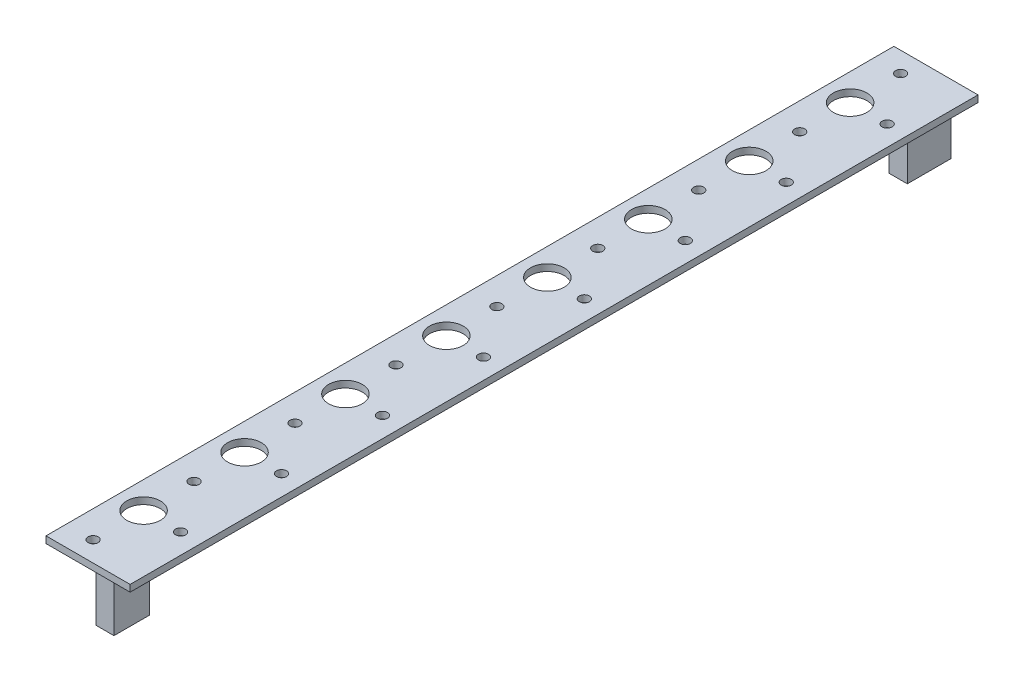
from build123d import *

# Parameters (mm, degrees)
ESQUISSE1_W        = 25
ESQUISSE1_H        = 252
ESQUISSE1_R        = 5
ESQUISSE1_R_2      = 1.5
BOSS_EXTRU_1_DEPTH = 2
ESQUISSE2_W        = 5.4
ESQUISSE2_H        = 13
ESQUISSE2_H_2      = 10.6
BOSS_EXTRU_2_DEPTH = 16


with BuildPart() as part:
    # Esquisse1 → Boss.-Extru.1 (new body)
    with BuildSketch(Plane(origin=(0, 0, 0), x_dir=(1, 0, 0), z_dir=(0, 1, 0))):
        Rectangle(ESQUISSE1_W, ESQUISSE1_H)
        with Locations((-4.5, 105)):
            Circle(ESQUISSE1_R, mode=Mode.SUBTRACT)
        with Locations((6.5, 105)):
            Circle(ESQUISSE1_R_2, mode=Mode.SUBTRACT)
        with Locations((-4.5, 75)):
            Circle(ESQUISSE1_R, mode=Mode.SUBTRACT)
        with Locations((6.5, 75)):
            Circle(ESQUISSE1_R_2, mode=Mode.SUBTRACT)
        with Locations((-4.5, 45)):
            Circle(ESQUISSE1_R, mode=Mode.SUBTRACT)
        with Locations((6.5, 45)):
            Circle(ESQUISSE1_R_2, mode=Mode.SUBTRACT)
        with Locations((-4.5, 15)):
            Circle(ESQUISSE1_R, mode=Mode.SUBTRACT)
        with Locations((6.5, 15)):
            Circle(ESQUISSE1_R_2, mode=Mode.SUBTRACT)
        with Locations((-4.5, -15)):
            Circle(ESQUISSE1_R, mode=Mode.SUBTRACT)
        with Locations((6.5, -15)):
            Circle(ESQUISSE1_R_2, mode=Mode.SUBTRACT)
        with Locations((-4.5, -45)):
            Circle(ESQUISSE1_R, mode=Mode.SUBTRACT)
        with Locations((6.5, -45)):
            Circle(ESQUISSE1_R_2, mode=Mode.SUBTRACT)
        with Locations((-4.5, -75)):
            Circle(ESQUISSE1_R, mode=Mode.SUBTRACT)
        with Locations((6.5, -75)):
            Circle(ESQUISSE1_R_2, mode=Mode.SUBTRACT)
        with Locations((-4.5, -105)):
            Circle(ESQUISSE1_R, mode=Mode.SUBTRACT)
        with Locations((6.5, -105)):
            Circle(ESQUISSE1_R_2, mode=Mode.SUBTRACT)
        with Locations((-4.5, 120)):
            Circle(ESQUISSE1_R_2, mode=Mode.SUBTRACT)
        with Locations((-4.5, 90)):
            Circle(ESQUISSE1_R_2, mode=Mode.SUBTRACT)
        with Locations((-4.5, 60)):
            Circle(ESQUISSE1_R_2, mode=Mode.SUBTRACT)
        with Locations((-4.5, 30)):
            Circle(ESQUISSE1_R_2, mode=Mode.SUBTRACT)
        with Locations((-4.5, 0)):
            Circle(ESQUISSE1_R_2, mode=Mode.SUBTRACT)
        with Locations((-4.5, -30)):
            Circle(ESQUISSE1_R_2, mode=Mode.SUBTRACT)
        with Locations((-4.5, -60)):
            Circle(ESQUISSE1_R_2, mode=Mode.SUBTRACT)
        with Locations((-4.5, -90)):
            Circle(ESQUISSE1_R_2, mode=Mode.SUBTRACT)
        with Locations((-4.5, -120)):
            Circle(ESQUISSE1_R_2, mode=Mode.SUBTRACT)
    extrude(amount=BOSS_EXTRU_1_DEPTH)

    # Esquisse2 → Boss.-Extru.2 (add)
    with BuildSketch(Plane.XZ):
        with Locations((4.2, -117.1)):
            Rectangle(ESQUISSE2_W, ESQUISSE2_H)
        with Locations((2.6, 118.3)):
            Rectangle(ESQUISSE2_W, ESQUISSE2_H_2)
    extrude(amount=BOSS_EXTRU_2_DEPTH)


solid = part.part
